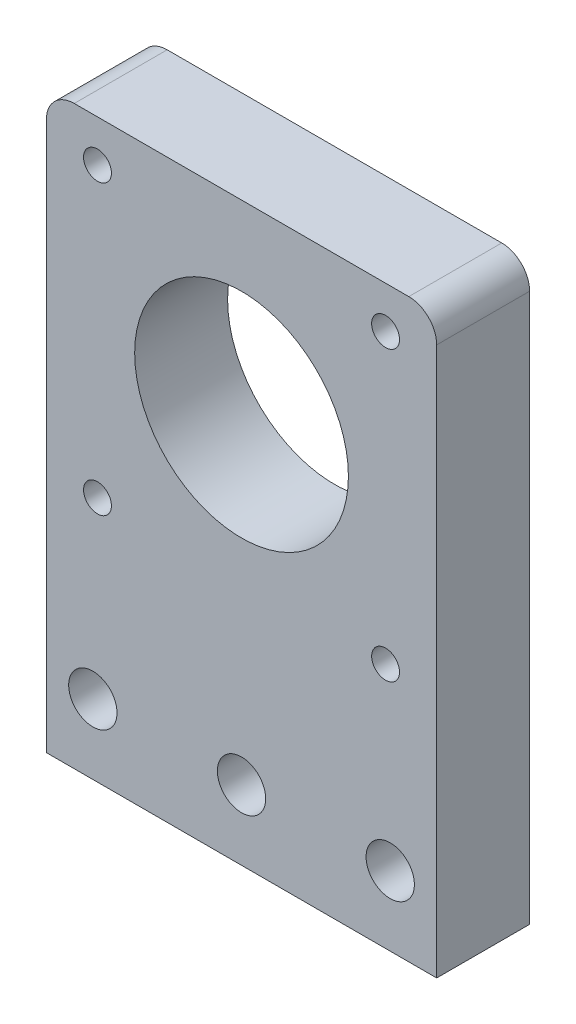
from build123d import *

# Parameters (mm, degrees)
SKETCH1_W           = 42
SKETCH1_H           = 62
SKETCH1_R           = 11.5
BOSS_EXTRUDE1_DEPTH = 10
FILLET2_R           = 3
SKETCH2_R           = 1.5
CUT_EXTRUDE1_DEPTH  = 11
SKETCH3_R           = 2.6
CUT_EXTRUDE2_DEPTH  = 11


with BuildPart() as part:
    # Sketch1 → Boss-Extrude1 (new body)
    with BuildSketch(Plane.XY):
        with Locations((21, 31)):
            Rectangle(SKETCH1_W, SKETCH1_H)
        with Locations((21, 42)):
            Circle(SKETCH1_R, mode=Mode.SUBTRACT)
    extrude(amount=BOSS_EXTRUDE1_DEPTH)

    # Fillet2
    fillet2_edges = [part.edges().sort_by_distance(p)[0] for p in [
        (0, 62, 5),
        (42, 62, 5),
    ]]
    fillet(fillet2_edges, radius=FILLET2_R)

    # Sketch2 → Cut-Extrude1 (cut, through all)
    with BuildSketch(Plane.XY.offset(10)):
        with Locations((5.5, 57.5)):
            Circle(SKETCH2_R)
        with Locations((36.5, 57.5)):
            Circle(SKETCH2_R)
        with Locations((5.5, 26.5)):
            Circle(SKETCH2_R)
        with Locations((36.5, 26.5)):
            Circle(SKETCH2_R)
    extrude(amount=-CUT_EXTRUDE1_DEPTH, mode=Mode.SUBTRACT)

    # Sketch3 → Cut-Extrude2 (cut, through all)
    with BuildSketch(Plane.XY.offset(10)):
        with Locations((5, 7.5)):
            Circle(SKETCH3_R)
        with Locations((21, 7.5)):
            Circle(SKETCH3_R)
        with Locations((37, 7.5)):
            Circle(SKETCH3_R)
    extrude(amount=-CUT_EXTRUDE2_DEPTH, mode=Mode.SUBTRACT)


solid = part.part
